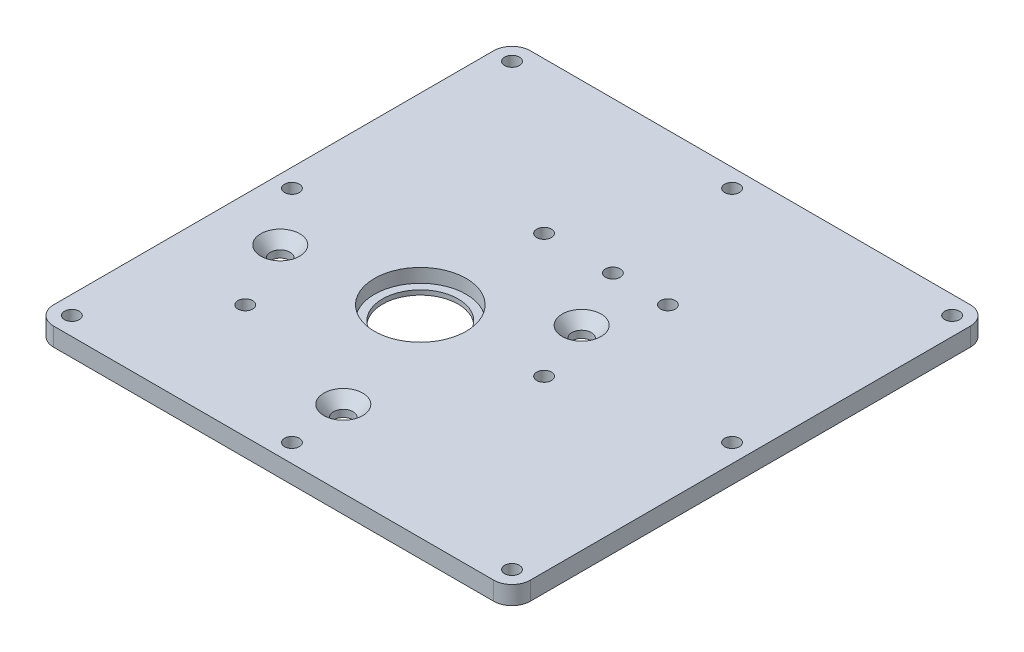
from build123d import *

# Parameters (mm, degrees)
SKETCH1_W                                    = 165.1
SKETCH1_H                                    = 165.1
SKETCH1_R                                    = 13.096875
SKETCH1_R_2                                  = 1.5875
BOSS_EXTRUDE1_DEPTH                          = 6.35
SKETCH3_R                                    = 15.875
CUT_EXTRUDE1_DEPTH                           = 4.7625
CSK_FOR_1_4_FLAT_HEAD_SOCKET_CAP_SCR_2_COUNT = 2
CSK_FOR_1_4_FLAT_HEAD_SOCKET_CAP_SCR_2_PITCH = 81.28
CSK_FOR_1_4_FLAT_HEAD_SOCKET_CAP_SCR_3_COUNT = 2
CSK_FOR_1_4_FLAT_HEAD_SOCKET_CAP_SCR_3_PITCH = 69.342
FILLET1_R                                    = 6.35
F_10_CLEARANCE_HOLE1_D                       = 5.1054
F_1_4_20_TAPPED_HOLE1_D                      = 5.1054
F_1_4_20_TAPPED_HOLE1_DEPTH                  = 16.002
F_1_4_20_TAPPED_HOLE1_TIP                    = 1.533816902
F_10_CLEARANCE_HOLE2_D                       = 5.1054
SKETCH16_R                                   = 8.9027
SKETCH16_R_2                                 = 19.446875
SKETCH16_R_3                                 = 7.332969894
SKETCH16_R_4                                 = 9.7282
CUT_EXTRUDE2_DEPTH                           = 3.175
FILLET2_R                                    = 3.175


with BuildPart() as part:
    # Sketch1 → Boss-Extrude1 (new body)
    with BuildSketch(Plane(origin=(0, 0, 0), x_dir=(1, 0, 0), z_dir=(0, 1, 0))):
        Rectangle(SKETCH1_W, SKETCH1_H)
        with Locations((-19.05, -12.7)):
            Circle(SKETCH1_R, mode=Mode.SUBTRACT)
        with Locations((23.8125, -12.7)):
            Circle(SKETCH1_R_2, mode=Mode.SUBTRACT)
    extrude(amount=BOSS_EXTRUDE1_DEPTH)

    # Sketch3 → Cut-Extrude1 (cut)
    with BuildSketch(Plane.XZ.offset(-6.35)):
        with Locations((-19.05, 12.7)):
            Circle(SKETCH3_R)
    extrude(amount=CUT_EXTRUDE1_DEPTH, mode=Mode.SUBTRACT)

    # Sketch8 → CSK for 1/4 Flat Head Socket Cap Screw1 (revolve, cut)
    with BuildSketch(Plane(origin=(-61.255776472, 6.35, 18.990629251), x_dir=(0, 0, 1), z_dir=(1, 0, 0))):
        Polygon((0, 0), (0, 6.35), (3.3782, 6.35), (3.3782, 3.871564875), (6.7437, 0), align=None)
    csk_for_1_4_flat_head_socket_cap_screw1 = revolve(axis=Axis((-61.255776472, 12.7, 18.990629251), (0, -1, 0)), mode=Mode.SUBTRACT)

    # CSK for 1_4 Flat Head Socket Cap Scr 2: CSK for 1/4 Flat Head Socket Cap Screw1 ×2
    with Locations(*[Vector(0.938375852, 0, -0.345616493) * (i * CSK_FOR_1_4_FLAT_HEAD_SOCKET_CAP_SCR_2_PITCH) for i in range(1, CSK_FOR_1_4_FLAT_HEAD_SOCKET_CAP_SCR_2_COUNT)]):
        add(csk_for_1_4_flat_head_socket_cap_screw1, mode=Mode.SUBTRACT)

    # CSK for 1_4 Flat Head Socket Cap Scr 3: CSK for 1/4 Flat Head Socket Cap Screw1 ×2
    with Locations(*[Vector(0.846756316, 0, 0.531980959) * (i * CSK_FOR_1_4_FLAT_HEAD_SOCKET_CAP_SCR_3_PITCH) for i in range(1, CSK_FOR_1_4_FLAT_HEAD_SOCKET_CAP_SCR_3_COUNT)]):
        add(csk_for_1_4_flat_head_socket_cap_screw1, mode=Mode.SUBTRACT)

    # Fillet1
    fillet1_edges = [part.edges().sort_by_distance(p)[0] for p in [
        (-82.55, 3.175, -82.55),
        (82.55, 3.175, -82.55),
        (82.55, 3.175, 82.55),
        (-82.55, 3.175, 82.55),
    ]]
    fillet(fillet1_edges, radius=FILLET1_R)

    # #10 Clearance Hole1 (through all)
    with Locations(Plane(origin=(0, 6.35, 0), x_dir=(1, 0, 0), z_dir=(0, 1, 0))):
        with Locations((-76.2, -76.2), (-76.2, 76.2), (76.2, 76.2), (76.2, -76.2), (0, 76.2), (0, -76.2), (-76.2, 0), (76.2, 0)):
            Hole(F_10_CLEARANCE_HOLE1_D / 2)

    # 1/4-20 Tapped Hole1
    with Locations(Plane(origin=(0, 6.35, 0), x_dir=(1, 0, 0), z_dir=(0, 1, 0))):
        with Locations((23.8125, -12.7), (-49.358364409, -43.008364409), (-19.05, 30.1625), (-19.05, -12.7)):
            Hole(F_1_4_20_TAPPED_HOLE1_D / 2, depth=F_1_4_20_TAPPED_HOLE1_DEPTH)
            with Locations((0, 0, -(F_1_4_20_TAPPED_HOLE1_DEPTH + F_1_4_20_TAPPED_HOLE1_TIP / 2))):  # 118° drill point
                Cone(0, F_1_4_20_TAPPED_HOLE1_D / 2, F_1_4_20_TAPPED_HOLE1_TIP, mode=Mode.SUBTRACT)

    # #10 Clearance Hole2 (through all)
    with Locations(Plane(origin=(0, 6.35, 0), x_dir=(1, 0, 0), z_dir=(0, 1, 0))):
        with Locations((23.8125, 30.1625), (4.7625, 30.1625)):
            Hole(F_10_CLEARANCE_HOLE2_D / 2)

    # Sketch16 → Cut-Extrude2 (cut)
    with BuildSketch(Plane.XZ):
        with BuildLine():
            Line((-69.85, -69.85), (69.85, -69.85))
            Line((69.85, -69.85), (69.85, 69.85))
            Line((69.85, 69.85), (-69.85, 69.85))
            Line((-69.85, 69.85), (-69.85, 23.548830343))
            ThreePointArc((-69.85, 23.548830343), (-51.527576472, 18.990629251), (-69.85, 14.432428159))
            Line((-69.85, 14.432428159), (-69.85, -69.85))
        make_face()
        with Locations((-19.05, -30.1625)):
            Circle(SKETCH16_R, mode=Mode.SUBTRACT)
        with BuildLine():
            ThreePointArc((26.701812238, 4.279195877), (25.431817694, 3.945808004), (24.126599504, 3.802842657))
            ThreePointArc((24.126599504, 3.802842657), (21.821072601, 1.296842431), (21.77826487, -2.108103813))
            ThreePointArc((21.77826487, -2.108103813), (22.726285123, -3.169779078), (23.509240054, -4.358424671))
            ThreePointArc((23.509240054, -4.358424671), (24.7390513, -9.398953448), (23.203012358, -14.354753124))
            ThreePointArc((23.203012358, -14.354753124), (22.778841422, -18.668760314), (26.026775263, -21.539562429))
            ThreePointArc((26.026775263, -21.539562429), (31.576627013, -34.518690884), (17.607086431, -36.546143923))
            ThreePointArc((17.607086431, -36.546143923), (14.2875, -35.198574694), (10.967913569, -36.546143923))
            ThreePointArc((10.967913569, -36.546143923), (-3.202448667, -34.139642192), (3.388256312, -21.366505367))
            ThreePointArc((3.388256312, -21.366505367), (6.975124047, -18.66147581), (6.716089287, -14.176422182))
            ThreePointArc((6.716089287, -14.176422182), (6.098886497, -5.210907818), (13.090804558, 0.434840043))
            ThreePointArc((13.090804558, 0.434840043), (13.280061368, 0.471090255), (13.469999062, 0.503584721))
            ThreePointArc((13.469999062, 0.503584721), (16.805475765, 3.267308056), (16.522545733, 7.589752053))
            ThreePointArc((16.522545733, 7.589752053), (26.565926614, 21.166209847), (26.701812238, 4.279195877))
        make_face(mode=Mode.SUBTRACT)
        with Locations((-19.05, 12.7)):
            Circle(SKETCH16_R_2, mode=Mode.SUBTRACT)
        with Locations((-49.358364409, 43.008364409)):
            Circle(SKETCH16_R_3, mode=Mode.SUBTRACT)
        with Locations((-2.54, 55.879252935)):
            Circle(SKETCH16_R_4, mode=Mode.SUBTRACT)
    extrude(amount=-CUT_EXTRUDE2_DEPTH, mode=Mode.SUBTRACT)

    # Fillet2
    fillet2_edges = [part.edges().sort_by_distance(p)[0] for p in [
        (-69.85, 1.5875, 14.432428159),
        (-69.85, 1.5875, 23.548830343),
        (-69.85, 1.5875, 69.85),
        (69.85, 1.5875, 69.85),
        (69.85, 1.5875, -69.85),
        (-69.85, 1.5875, -69.85),
    ]]
    fillet(fillet2_edges, radius=FILLET2_R)


solid = part.part
